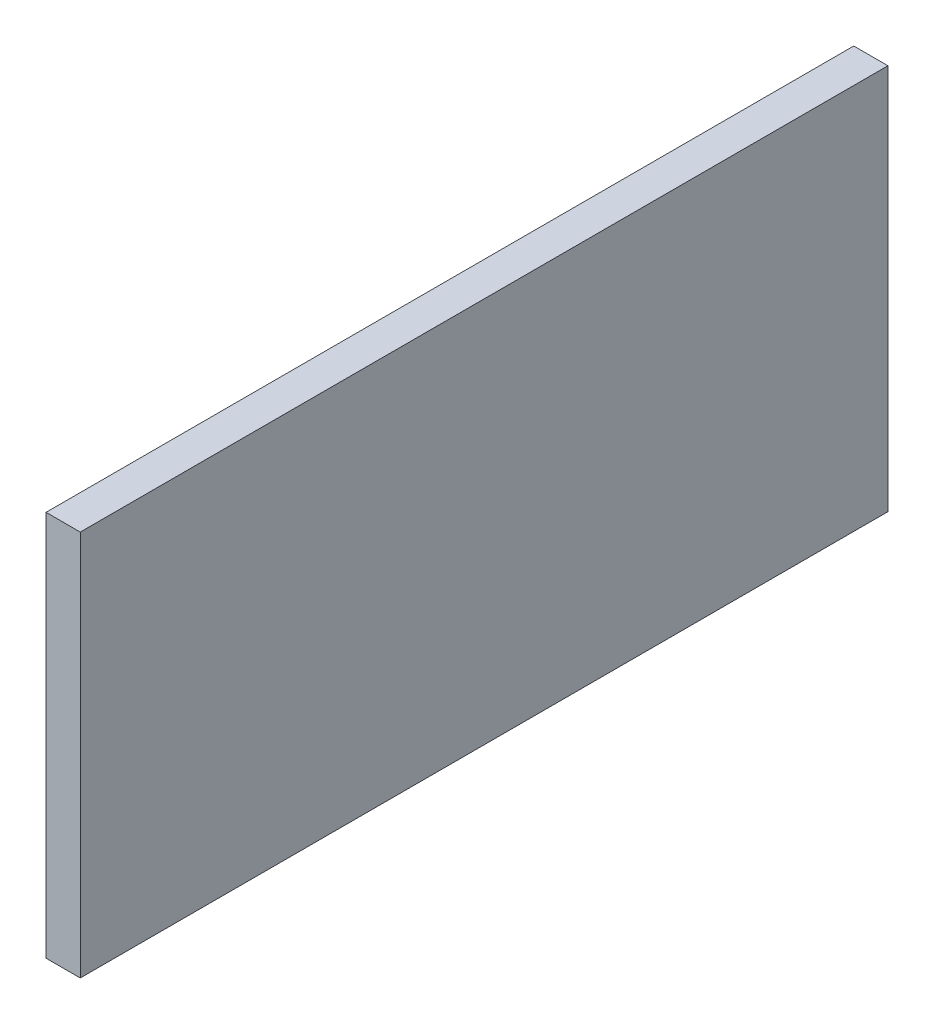
from build123d import *

# Parameters (mm, degrees)
SKETCH1_W           = 70.850574713
SKETCH1_H           = 33.876964868
BOSS_EXTRUDE1_DEPTH = 3


with BuildPart() as part:
    # Sketch1 → Boss-Extrude1 (new body)
    with BuildSketch(Plane(origin=(0, 0, 0), x_dir=(0, 0, -1), z_dir=(1, 0, 0))):
        with Locations((-29.081748838, -25.4548746)):
            Rectangle(SKETCH1_W, SKETCH1_H)
    extrude(amount=BOSS_EXTRUDE1_DEPTH)


solid = part.part
